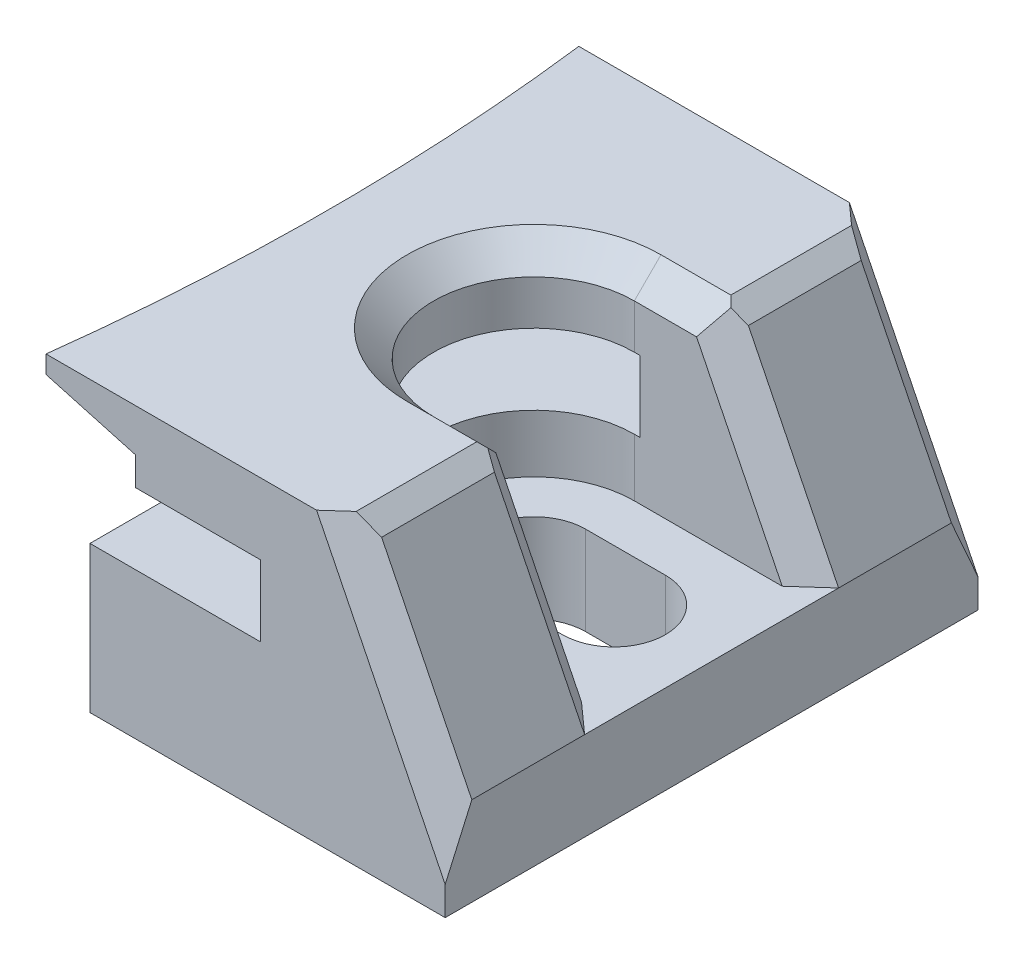
from build123d import *

# Parameters (mm, degrees)
BOSS_EXTRUDE1_DEPTH      = 15
BOSS_EXTRUDE1_DEPTH_BACK = 15
SKETCH2_W                = 10.45
SKETCH2_H                = 4
CUT_EXTRUDE3_DEPTH       = 28.414640249
CUT_EXTRUDE7_DEPTH       = 5
CHAMFER1_SIZE            = 1.5
CHAMFER2_SIZE            = 0.5
CHAMFER2_SIZE2           = 1.104400541
CHAMFER2_EDGE_2_SIZE     = 0.5
CHAMFER2_EDGE_2_SIZE2    = 1.104400541


with BuildPart() as part:
    # Sketch1 → Boss-Extrude1 (new, two sides)
    with BuildSketch(Plane.XY) as boss_extrude1_sk:
        Polygon((20, 5), (20, 0), (0, 0), (0, 12.25), (-5.154982838, 12.25), (-5.154982838, 16.25), (14.432786844, 16.25), align=None)
    extrude(amount=BOSS_EXTRUDE1_DEPTH)
    extrude(boss_extrude1_sk.sketch, amount=-BOSS_EXTRUDE1_DEPTH_BACK)

    # Sketch2 → Cut-Revolve2 (revolve, cut)
    with BuildSketch(Plane.XY):
        with Locations((5.225, 10.25)):
            Rectangle(SKETCH2_W, SKETCH2_H)
        Polygon((-1.55, 16.25), (-5.154982838, 16.25), (-5.154982838, 12.25), (0, 12.25), (3.45, 12.25), (3.45, 13.85), (-1.55, 15.25), align=None)
    revolve(axis=Axis((-123.55, 0, 0), (0, 1, 0)), mode=Mode.SUBTRACT)

    # Sketch5 → Cut-Extrude3 (cut, through all)
    with BuildSketch(Plane(origin=(0, 5, 0), x_dir=(-1, 0, 0), z_dir=(0, -1, 0))):
        with BuildLine():
            Line((-20, -5.65), (-10, -5.65))
            ThreePointArc((-10, -5.65), (-4.35, 0), (-10, 5.65))
            Line((-10, 5.65), (-20, 5.65))
            Line((-20, 5.65), (-20, -5.65))
        make_face()
    extrude(amount=-CUT_EXTRUDE3_DEPTH, mode=Mode.SUBTRACT)

    # Sketch6 → Cut-Extrude7 (cut)
    with BuildSketch(Plane(origin=(0, 5, 0), x_dir=(1, 0, 0), z_dir=(0, 1, 0))):
        with BuildLine():
            Line((10, 2.9), (14.5, 2.9))
            ThreePointArc((14.5, 2.9), (17.4, 0), (14.5, -2.9))
            Line((14.5, -2.9), (10, -2.9))
            ThreePointArc((10, -2.9), (7.1, 0), (10, 2.9))
        make_face()
    extrude(amount=-CUT_EXTRUDE7_DEPTH, mode=Mode.SUBTRACT)

    # Chamfer1
    chamfer1_edges = [part.edges().sort_by_distance(p)[0] for p in [
        (17.216393422, 10.625, 15),
        (12.216393422, 16.25, -5.65),
        (12.216393422, 16.25, 5.65),
        (17.216393422, 10.625, 5.65),
        (17.216393422, 10.625, -5.65),
        (4.35, 16.25, 0),
        (17.216393422, 10.625, -15),
    ]]
    chamfer(chamfer1_edges, length=CHAMFER1_SIZE)

    # Chamfer2
    chamfer2_edges = [part.edges().sort_by_distance(p)[0] for p in [
        (14.432786844, 16.25, -10.325),
    ]]
    chamfer2_side = [part.faces().sort_by_distance(p)[0] for p in [
        (5.141762366, 16.25, -14.655631739),
    ]]
    chamfer(chamfer2_edges, length=CHAMFER2_SIZE, length2=CHAMFER2_SIZE2, reference=chamfer2_side[0])

    # Chamfer2 edge 2
    chamfer2_edge_2_edges = [part.edges().sort_by_distance(p)[0] for p in [
        (14.432786844, 16.25, 10.325),
    ]]
    chamfer2_edge_2_side = [part.faces().sort_by_distance(p)[0] for p in [
        (5.141762366, 16.25, -14.655631739),
    ]]
    chamfer(chamfer2_edge_2_edges, length=CHAMFER2_EDGE_2_SIZE, length2=CHAMFER2_EDGE_2_SIZE2, reference=chamfer2_edge_2_side[0])


solid = part.part
